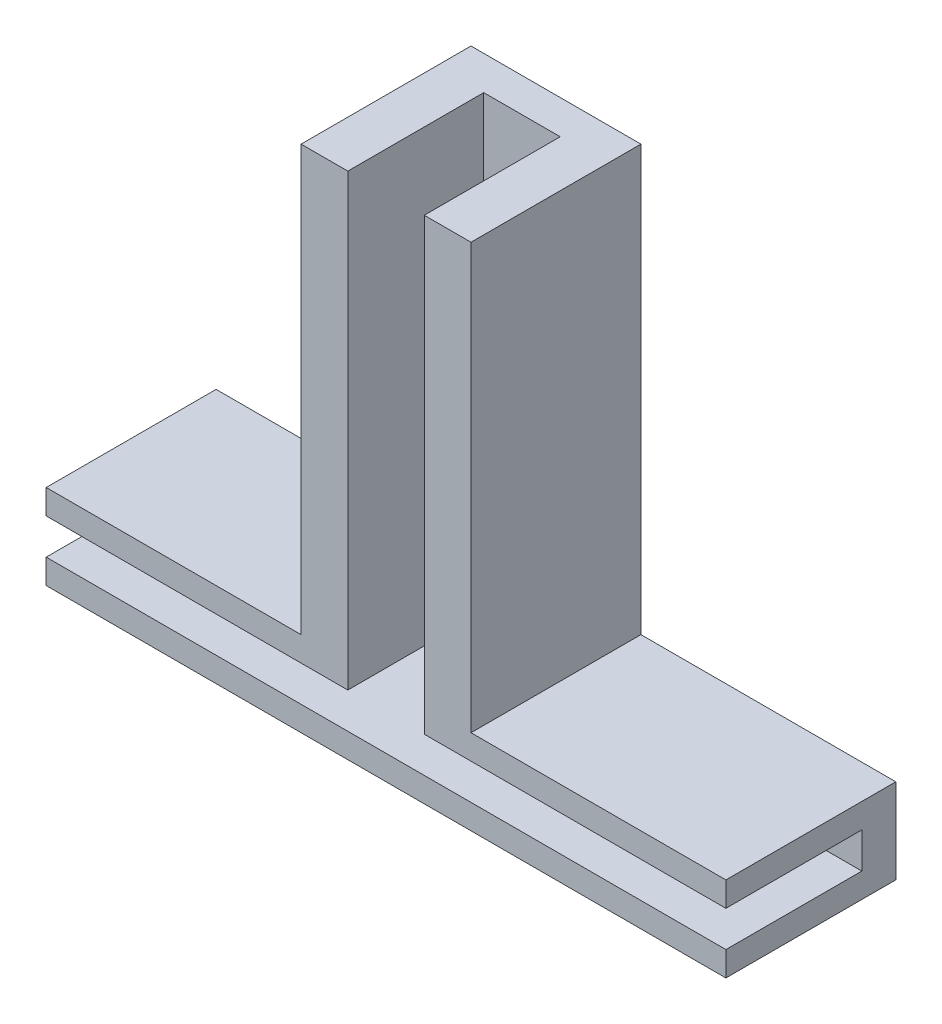
from build123d import *

# Parameters (mm, degrees)
SKETCH1_W           = 40
SKETCH1_H           = 10
BOSS_EXTRUDE1_DEPTH = 5
SKETCH2_W           = 8
SKETCH2_H           = 2.1
CUT_EXTRUDE2_DEPTH  = 41
SKETCH3_W           = 10
SKETCH3_H           = 25
BOSS_EXTRUDE2_DEPTH = 10
SKETCH4_W           = 2.25
SKETCH4_H           = 26.45
CUT_EXTRUDE3_DEPTH  = 8


with BuildPart() as part:
    # Sketch1 → Boss-Extrude1 (new body)
    with BuildSketch(Plane(origin=(0, 0, 0), x_dir=(1, 0, 0), z_dir=(0, 1, 0))):
        Rectangle(SKETCH1_W, SKETCH1_H)
    extrude(amount=BOSS_EXTRUDE1_DEPTH)

    # Sketch2 → Cut-Extrude2 (cut, through all)
    with BuildSketch(Plane(origin=(20, 0, 0), x_dir=(0, 0, -1), z_dir=(1, 0, 0))):
        with Locations((-1, 2.5)):
            Rectangle(SKETCH2_W, SKETCH2_H)
    extrude(amount=-CUT_EXTRUDE2_DEPTH, mode=Mode.SUBTRACT)

    # Sketch3 → Boss-Extrude2 (add)
    with BuildSketch(Plane(origin=(0, 0, -5), x_dir=(-1, 0, 0), z_dir=(0, 0, -1))):
        with Locations((0, 17.5)):
            Rectangle(SKETCH3_W, SKETCH3_H)
    extrude(amount=-BOSS_EXTRUDE2_DEPTH)

    # Sketch4 → Cut-Extrude3 (cut)
    with BuildSketch(Plane.XY.offset(5)):
        with Locations((-1.125, 16.775)):
            Rectangle(SKETCH4_W, SKETCH4_H)
        with Locations((1.125, 16.775)):
            Rectangle(SKETCH4_W, SKETCH4_H)
    extrude(amount=-CUT_EXTRUDE3_DEPTH, mode=Mode.SUBTRACT)


solid = part.part
